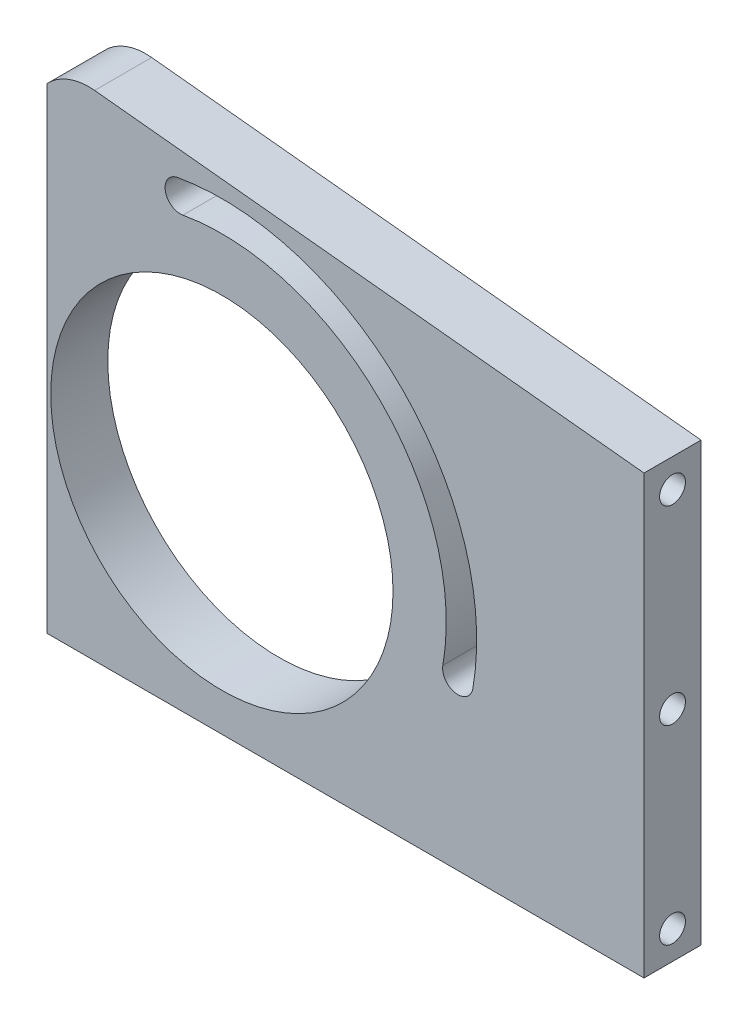
from build123d import *

# Parameters (mm, degrees)
CROQUIS1_R                = 45
SALIENTE_EXTRUIR1_DEPTH   = 7.5
TALADRO_ROSCADO_M81_D     = 6.8
TALADRO_ROSCADO_M81_DEPTH = 20
TALADRO_ROSCADO_M81_TIP   = 2.042926105
TALADRO_ROSCADO_M82_D     = 6.8
TALADRO_ROSCADO_M82_DEPTH = 10
TALADRO_ROSCADO_M82_TIP   = 2.042926105
CORTAR_EXTRUIR1_DEPTH     = 167.9


with BuildPart() as part:
    # Croquis1 → Saliente-Extruir1 (new body, symmetric)
    with BuildSketch(Plane.XY):
        with BuildLine():
            Line((-50, -55), (-50, 59.973896209))
            ThreePointArc((-50, 59.973896209), (-45.047974372, 71.111140529), (-33.461571863, 74.894795608))
            Line((-33.461571863, 74.894795608), (111, 60))
            Line((111, 60), (111, -55))
            Line((111, -55), (-50, -55))
        make_face()
        Circle(CROQUIS1_R, mode=Mode.SUBTRACT)
        with BuildLine():
            ThreePointArc((65.982119452, -11.634427904), (47.376154339, 47.376154339), (-11.634427904, 65.982119452))
            ThreePointArc((-11.634427904, 65.982119452), (-14.879066205, 61.348295729), (-10.245242482, 58.103657428))
            ThreePointArc((-10.245242482, 58.103657428), (41.71930009, 41.71930009), (58.103657428, -10.245242482))
            ThreePointArc((58.103657428, -10.245242482), (61.348295729, -14.879066205), (65.982119452, -11.634427904))
        make_face(mode=Mode.SUBTRACT)
    extrude(amount=SALIENTE_EXTRUIR1_DEPTH, both=True)

    # Taladro roscado M81
    with Locations(Plane(origin=(111, 0, 0), x_dir=(0, 0, -1), z_dir=(1, 0, 0))):
        with Locations((0, 52.5), (0, 2.5), (0, -47.5)):
            Hole(TALADRO_ROSCADO_M81_D / 2, depth=TALADRO_ROSCADO_M81_DEPTH)
            with Locations((0, 0, -(TALADRO_ROSCADO_M81_DEPTH + TALADRO_ROSCADO_M81_TIP / 2))):  # 118° drill point
                Cone(0, TALADRO_ROSCADO_M81_D / 2, TALADRO_ROSCADO_M81_TIP, mode=Mode.SUBTRACT)

    # Taladro roscado M82
    with Locations(Plane.XZ.offset(55)):
        with Locations((-42.5, 0), (16.3, 0), (75.1, 0)):
            Hole(TALADRO_ROSCADO_M82_D / 2, depth=TALADRO_ROSCADO_M82_DEPTH)
            with Locations((0, 0, -(TALADRO_ROSCADO_M82_DEPTH + TALADRO_ROSCADO_M82_TIP / 2))):  # 118° drill point
                Cone(0, TALADRO_ROSCADO_M82_D / 2, TALADRO_ROSCADO_M82_TIP, mode=Mode.SUBTRACT)

    # Croquis7 → Cortar-Extruir1 (cut)
    with BuildSketch(Plane.XZ.offset(55)):
        Polygon((-50, 7.5), (-50, 3.5), (-46, 7.5), align=None)
        Polygon((-50, -7.5), (-50, -3.5), (-46, -7.5), align=None)
    extrude(amount=-CORTAR_EXTRUIR1_DEPTH, mode=Mode.SUBTRACT)


solid = part.part
